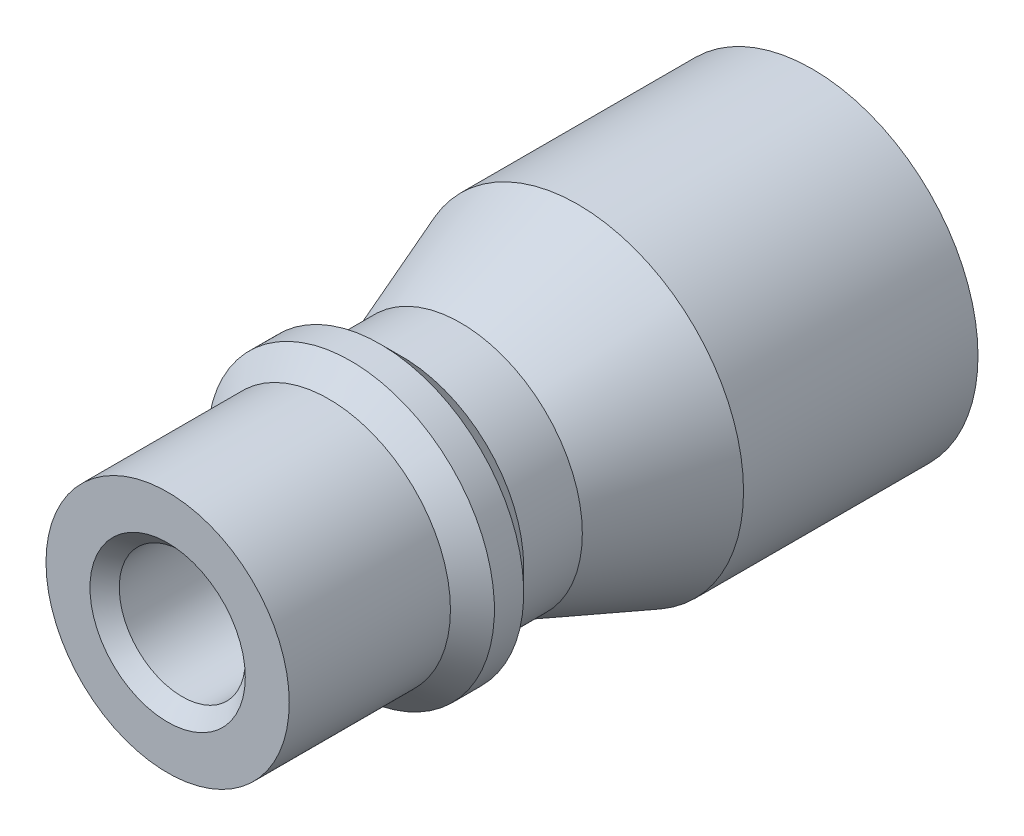
from build123d import *

# Parameters (mm, degrees)
SKETCH1_R           = 5.65
SKETCH1_R_2         = 3.65
BOSS_EXTRUDE1_DEPTH = 8
SKETCH3_R           = 5.65
SKETCH2_R           = 4.15
SKETCH4_R           = 3.65
CUT_EXTRUDE2_DEPTH  = 3
CUT_EXTRUDE2_TAPER  = 49
SKETCH6_R           = 4.15
SKETCH6_R_2         = 2.15
BOSS_EXTRUDE2_DEPTH = 10
CHAMFER1_SIZE       = 0.5
CHAMFER2_SIZE       = 0.5


with BuildPart() as part:
    # Sketch1 → Boss-Extrude1 (new body)
    with BuildSketch(Plane.XY):
        Circle(SKETCH1_R)
        Circle(SKETCH1_R_2, mode=Mode.SUBTRACT)
    extrude(amount=BOSS_EXTRUDE1_DEPTH)

    # Sketch3 → Loft1 section 0
    with BuildSketch(Plane.XY.offset(8)):
        Circle(SKETCH3_R)
    # Sketch2 → Loft1 section 1
    with BuildSketch(Plane.XY.offset(12)):
        Circle(SKETCH2_R)
    loft()

    # Sketch4 → Cut-Extrude2 (cut)
    with BuildSketch(Plane(origin=(0, 0, 8), x_dir=(-1, 0, 0), z_dir=(0, 0, -1))):
        Circle(SKETCH4_R)
    extrude(amount=-CUT_EXTRUDE2_DEPTH, taper=CUT_EXTRUDE2_TAPER, mode=Mode.SUBTRACT)

    # Sketch6 → Boss-Extrude2 (add)
    with BuildSketch(Plane.XY.offset(12)):
        Circle(SKETCH6_R)
        Circle(SKETCH6_R_2, mode=Mode.SUBTRACT)
    extrude(amount=BOSS_EXTRUDE2_DEPTH)

    # Sketch7 → Revolve1 (revolve)
    with BuildSketch(Plane(origin=(0, 0, 0), x_dir=(0, 0, -1), z_dir=(1, 0, 0))):
        Polygon((-14, 4.15), (-14.75, 4.9), (-15.75, 4.9), (-16.5, 4.15), align=None)
    revolve(axis=Axis((0, 0, -80.9), (0, 0, 1)))

    # Chamfer1
    chamfer1_edges = [part.edges().sort_by_distance(p)[0] for p in [
        (-3.65, 0, 0),
    ]]
    chamfer(chamfer1_edges, length=CHAMFER1_SIZE)

    # Chamfer2
    chamfer2_edges = [part.edges().sort_by_distance(p)[0] for p in [
        (-2.15, 0, 22),
    ]]
    chamfer(chamfer2_edges, length=CHAMFER2_SIZE)


solid = part.part
